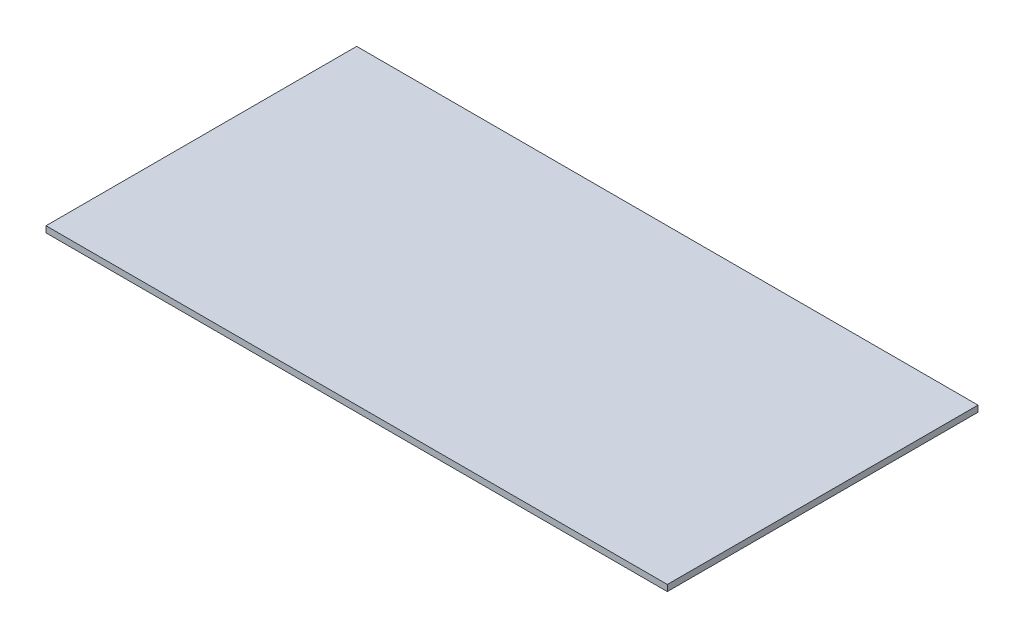
from build123d import *

# Parameters (mm, degrees)
SKETCH1_W           = 1000
SKETCH1_H           = 500
BOSS_EXTRUDE1_DEPTH = 10


with BuildPart() as part:
    # Sketch1 → Boss-Extrude1 (new body)
    with BuildSketch(Plane(origin=(0, 0, 0), x_dir=(1, 0, 0), z_dir=(0, 1, 0))):
        Rectangle(SKETCH1_W, SKETCH1_H)
    extrude(amount=BOSS_EXTRUDE1_DEPTH)


solid = part.part
